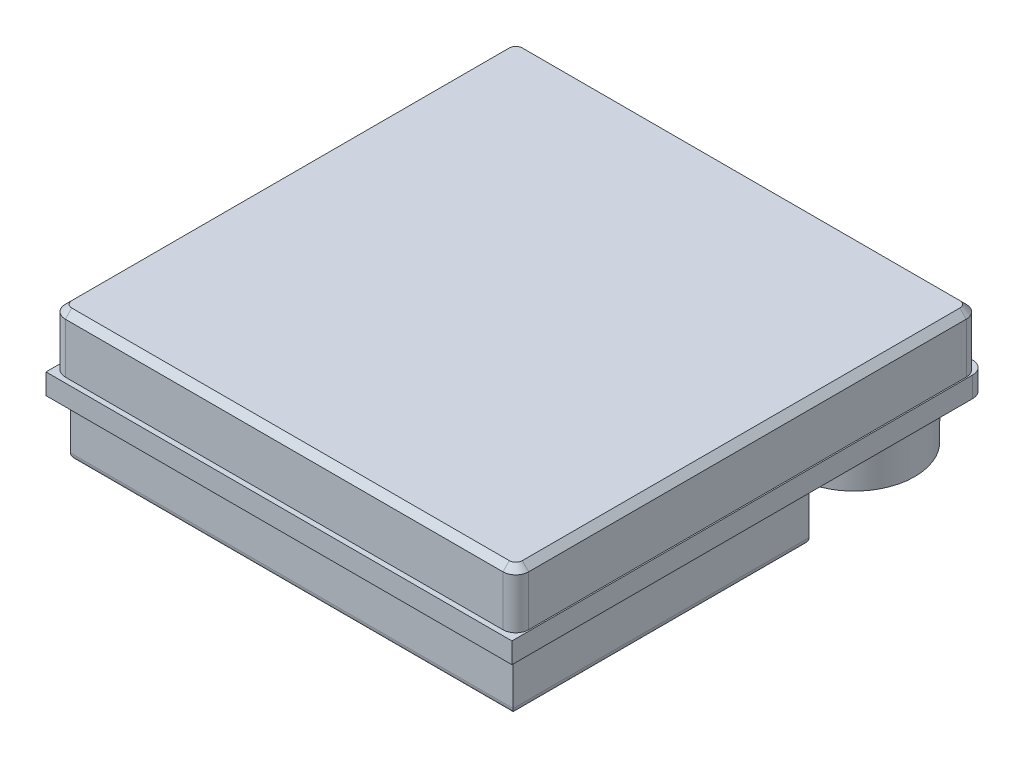
from build123d import *

# Parameters (mm, degrees)
SKETCH1_W           = 18.1
SKETCH1_H           = 18.4
BOSS_EXTRUDE1_DEPTH = 0.4
SKETCH2_W           = 18
SKETCH2_H           = 18
BOSS_EXTRUDE2_DEPTH = 2.2
SKETCH3_W           = 6.15
SKETCH3_H           = 4.3
BOSS_EXTRUDE3_DEPTH = 3
SKETCH4_W           = 5.15
SKETCH4_H           = 2
CUT_EXTRUDE1_DEPTH  = 3.5
SKETCH5_W           = 17.2
SKETCH5_H           = 11.5
BOSS_EXTRUDE4_DEPTH = 2.2
FILLET1_R           = 0.25
SKETCH6_R           = 2.35
BOSS_EXTRUDE5_DEPTH = 1.7
FILLET2_R           = 0.5
CHAMFER1_SIZE       = 0.25
FILLET3_R           = 0.5


with BuildPart() as part:
    # Sketch1 → Boss-Extrude1 (new body, symmetric)
    with BuildSketch(Plane(origin=(0, 0, 0), x_dir=(1, 0, 0), z_dir=(0, 1, 0))):
        Rectangle(SKETCH1_W, SKETCH1_H)
    extrude(amount=BOSS_EXTRUDE1_DEPTH, both=True)

    # Sketch2 → Boss-Extrude2 (add)
    with BuildSketch(Plane(origin=(0, 0.4, 0), x_dir=(1, 0, 0), z_dir=(0, 1, 0))):
        Rectangle(SKETCH2_W, SKETCH2_H)
    extrude(amount=BOSS_EXTRUDE2_DEPTH)

    # Sketch3 → Boss-Extrude3 (add)
    with BuildSketch(Plane.XZ.offset(0.4)):
        with Locations((0, -6.55)):
            Rectangle(SKETCH3_W, SKETCH3_H)
    extrude(amount=BOSS_EXTRUDE3_DEPTH)

    # Sketch4 → Cut-Extrude1 (cut)
    with BuildSketch(Plane(origin=(0, 0, -8.7), x_dir=(-1, 0, 0), z_dir=(0, 0, -1))):
        with Locations((0, -1.9)):
            Rectangle(SKETCH4_W, SKETCH4_H)
    extrude(amount=-CUT_EXTRUDE1_DEPTH, mode=Mode.SUBTRACT)

    # Sketch5 → Boss-Extrude4 (add)
    with BuildSketch(Plane.XZ.offset(0.4)):
        with Locations((0, 2.95)):
            Rectangle(SKETCH5_W, SKETCH5_H)
    extrude(amount=BOSS_EXTRUDE4_DEPTH)

    # Fillet1
    fillet1_edges = [part.edges().sort_by_distance(p)[0] for p in [
        (8.6, -2.6, 2.95),
        (0, -2.6, 8.7),
        (-8.6, -2.6, 2.95),
        (0, -2.6, -2.8),
    ]]
    fillet(fillet1_edges, radius=FILLET1_R)

    # Sketch6 → Boss-Extrude5 (add)
    with BuildSketch(Plane.XZ.offset(0.4)):
        with Locations((6.5, -6.65)):
            Circle(SKETCH6_R)
    extrude(amount=BOSS_EXTRUDE5_DEPTH)

    # Fillet2
    fillet2_edges = [part.edges().sort_by_distance(p)[0] for p in [
        (-9, 1.5, -9),
        (-9, 1.5, 9),
        (9, 1.5, 9),
        (9, 1.5, -9),
    ]]
    fillet(fillet2_edges, radius=FILLET2_R)

    # Chamfer1
    chamfer1_edges = [part.edges().sort_by_distance(p)[0] for p in [
        (-9, 2.6, 0),
        (0, 2.6, -9),
        (0, 2.6, 9),
        (9, 2.6, 0),
        (8.853553391, 2.6, -8.853553391),
        (8.853553391, 2.6, 8.853553391),
        (-8.853553391, 2.6, 8.853553391),
        (-8.853553391, 2.6, -8.853553391),
    ]]
    chamfer(chamfer1_edges, length=CHAMFER1_SIZE)

    # Fillet3
    fillet3_edges = [part.edges().sort_by_distance(p)[0] for p in [
        (-9.05, 0, -9.2),
        (9.05, 0, -9.2),
    ]]
    fillet(fillet3_edges, radius=FILLET3_R)


solid = part.part
